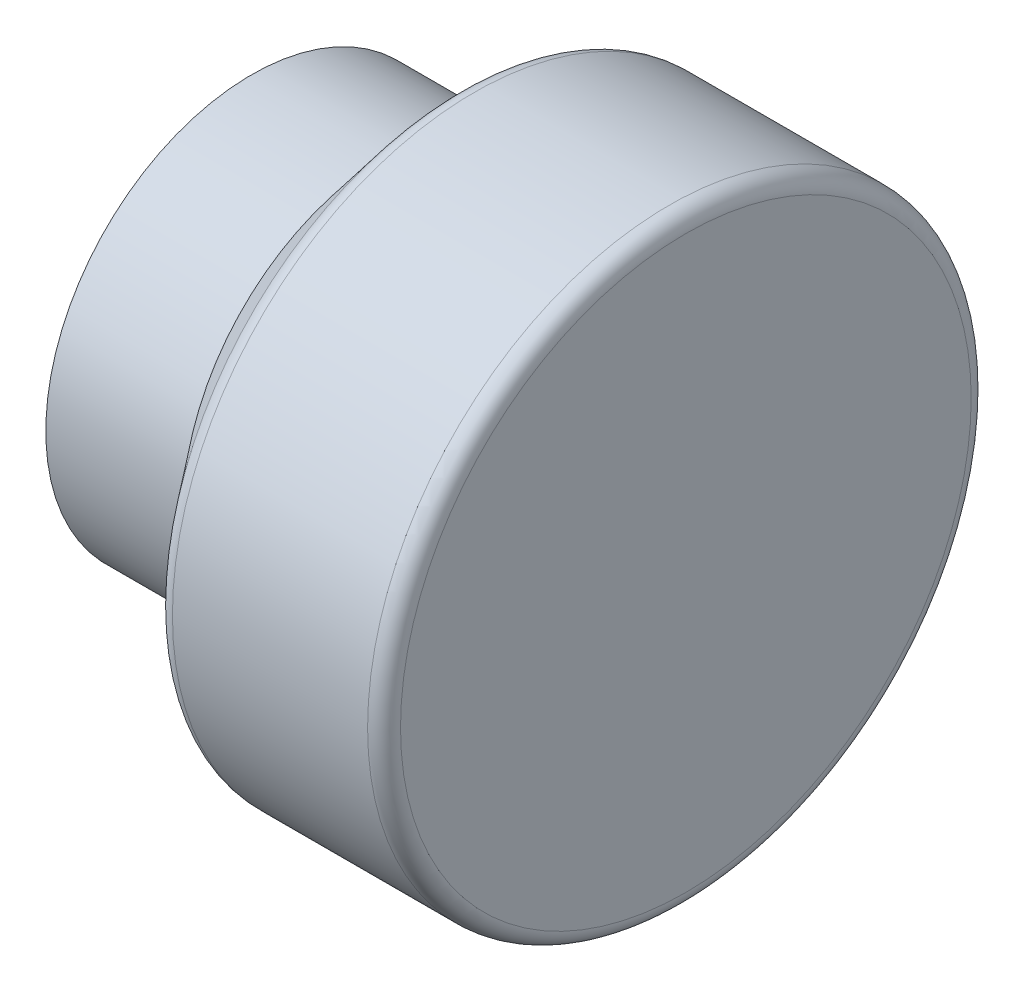
from build123d import *

# Parameters (mm, degrees)
FILLET1_R = 1.524


with BuildPart() as part:
    # Sketch1 → Revolve1 (revolve)
    with BuildSketch(Plane(origin=(0, 0, 0), x_dir=(1, 0, 0), z_dir=(0, 1, 0))):
        Polygon((-37.029204897, 17.4625), (-37.029204897, 19.05), (-24.329204897, 19.05), (-17.145, 27.94), (3.175, 27.94), (3.175, 0), (0, 0), (0, 24.765), (-15.628644606, 24.765), (-22.812849503, 15.875), (-35.429004897, 15.875), (-35.429004897, 17.4625), align=None)
    revolve(axis=Axis((3.175, 0, 0), (-1, 0, 0)))

    # Fillet1
    fillet1_edges = [part.edges().sort_by_distance(p)[0] for p in [
        (3.175, 0, 27.94),
        (-17.145, 0, 27.94),
    ]]
    fillet(fillet1_edges, radius=FILLET1_R)


solid = part.part
